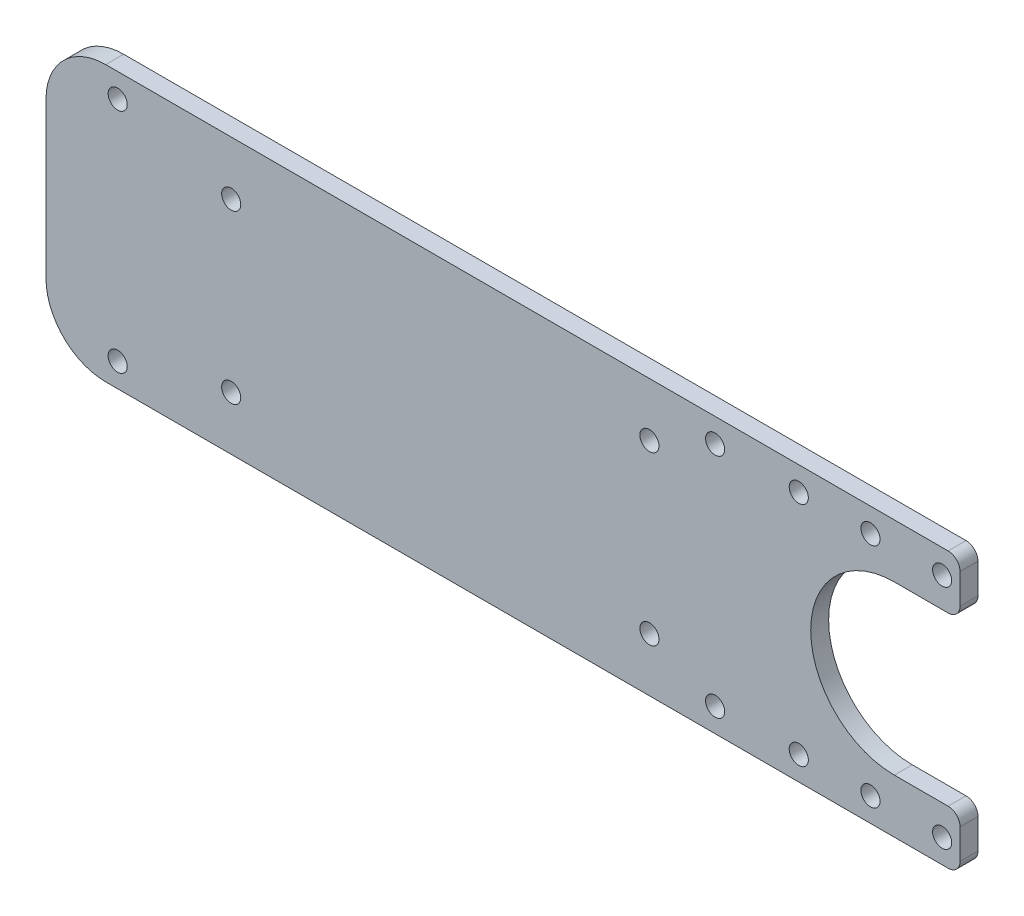
from build123d import *

# Parameters (mm, degrees)
SKETCH2_W           = 142
SKETCH2_H           = 46
SKETCH2_R           = 1.6
BOSS_EXTRUDE1_DEPTH = 3
SKETCH3_R           = 1.6
CUT_EXTRUDE1_DEPTH  = 4
SKETCH3_3_R         = 1.6
SKETCH3_3_W         = 11
SKETCH3_3_H         = 9
BOSS_EXTRUDE2_DEPTH = 3
FILLET2_R           = 2
FILLET3_R           = 2
FILLET4_R           = 10


with BuildPart() as part:
    # Sketch2 → Boss-Extrude1 (new body)
    with BuildSketch(Plane.XY):
        with Locations((15, 0)):
            Rectangle(SKETCH2_W, SKETCH2_H)
        with Locations((-25, -14)):
            Circle(SKETCH2_R, mode=Mode.SUBTRACT)
        with Locations((45, -14)):
            Circle(SKETCH2_R, mode=Mode.SUBTRACT)
        with Locations((-25, 14)):
            Circle(SKETCH2_R, mode=Mode.SUBTRACT)
        with Locations((45, 14)):
            Circle(SKETCH2_R, mode=Mode.SUBTRACT)
    extrude(amount=BOSS_EXTRUDE1_DEPTH)

    # Sketch3 → Cut-Extrude1 (cut, through all)
    with BuildSketch(Plane.XY.offset(3)):
        with BuildLine():
            Line((86, -14), (86, 14))
            ThreePointArc((86, 14), (72, 0), (86, -14))
        make_face()
        with Locations((82, 19)):
            Circle(SKETCH3_R)
        with Locations((56, 19)):
            Circle(SKETCH3_R)
        with Locations((-44, 19)):
            Circle(SKETCH3_R)
        with Locations((70, 19)):
            Circle(SKETCH3_R)
        with Locations((82, -19)):
            Circle(SKETCH3_R)
        with Locations((70, -19)):
            Circle(SKETCH3_R)
        with Locations((-44, -19)):
            Circle(SKETCH3_R)
        with Locations((56, -19)):
            Circle(SKETCH3_R)
    extrude(amount=-CUT_EXTRUDE1_DEPTH, mode=Mode.SUBTRACT)

    # Sketch3_3 → Boss-Extrude2 (add)
    with BuildSketch(Plane.XY.offset(3)):
        Polygon((97, 23), (86, 23), (86, 19), (86, 14), (97, 14), align=None)
        with Locations((94, 19)):
            Circle(SKETCH3_3_R, mode=Mode.SUBTRACT)
        with Locations((91.5, -18.5)):
            Rectangle(SKETCH3_3_W, SKETCH3_3_H)
        with Locations((94, -19)):
            Circle(SKETCH3_3_R, mode=Mode.SUBTRACT)
    extrude(amount=-BOSS_EXTRUDE2_DEPTH)

    # Fillet2
    fillet2_edges = [part.edges().sort_by_distance(p)[0] for p in [
        (97, 23, 1.5),
        (97, -23, 1.5),
    ]]
    fillet(fillet2_edges, radius=FILLET2_R)

    # Fillet3
    fillet3_edges = [part.edges().sort_by_distance(p)[0] for p in [
        (97, 14, 1.5),
        (97, -14, 1.5),
    ]]
    fillet(fillet3_edges, radius=FILLET3_R)

    # Fillet4
    fillet4_edges = [part.edges().sort_by_distance(p)[0] for p in [
        (-56, 23, 1.5),
        (-56, -23, 1.5),
    ]]
    fillet(fillet4_edges, radius=FILLET4_R)


solid = part.part
